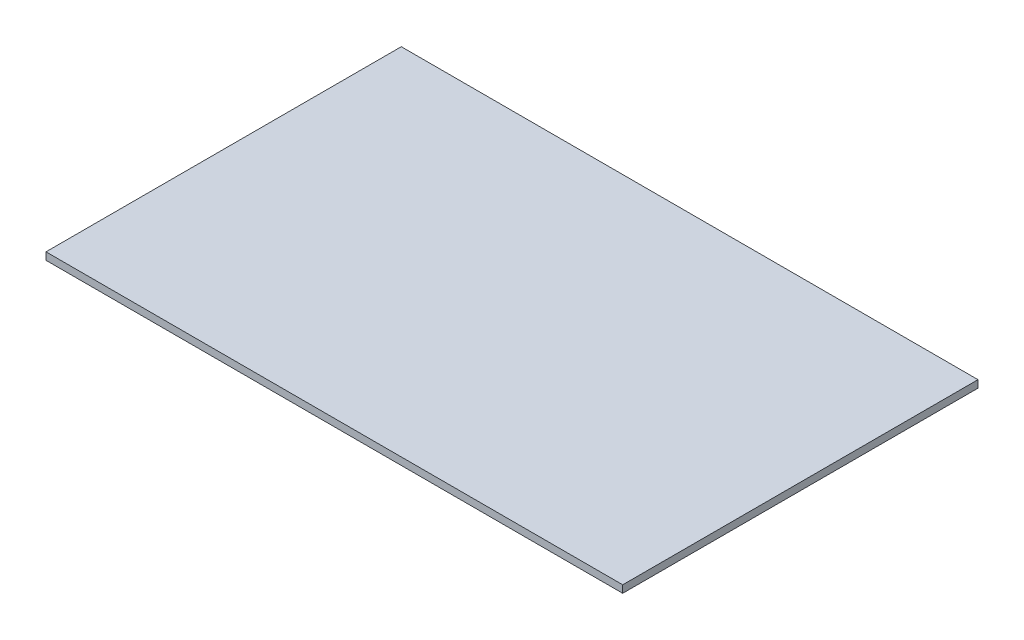
from build123d import *

# Parameters (mm, degrees)
SKETCH1_W           = 234.188
SKETCH1_H           = 144.272
BOSS_EXTRUDE1_DEPTH = 3


with BuildPart() as part:
    # Sketch1 → Boss-Extrude1 (new body)
    with BuildSketch(Plane(origin=(0, 0, 0), x_dir=(1, 0, 0), z_dir=(0, 1, 0))):
        Rectangle(SKETCH1_W, SKETCH1_H)
    extrude(amount=BOSS_EXTRUDE1_DEPTH)


solid = part.part
